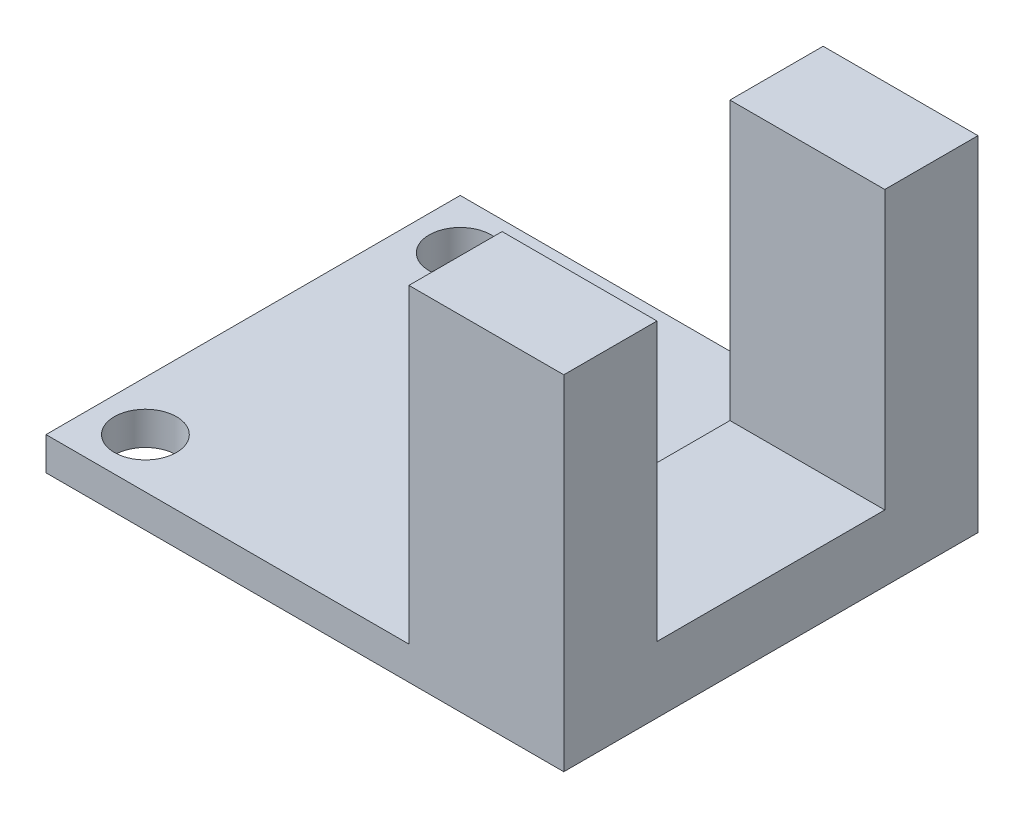
from build123d import *

# Parameters (mm, degrees)
SKETCH1_W           = 25
SKETCH1_H           = 20
BOSS_EXTRUDE1_DEPTH = 1.6
SKETCH2_W           = 7.477117313
SKETCH2_H           = 20
BOSS_EXTRUDE2_DEPTH = 15
SKETCH3_W           = 11
SKETCH3_H           = 13.40236223
CUT_EXTRUDE1_DEPTH  = 15
SKETCH4_R           = 1.5
CUT_EXTRUDE2_DEPTH  = 15


with BuildPart() as part:
    # Sketch1 → Boss-Extrude1 (new body)
    with BuildSketch(Plane(origin=(0, 0, 0), x_dir=(1, 0, 0), z_dir=(0, 1, 0))):
        Rectangle(SKETCH1_W, SKETCH1_H)
    extrude(amount=BOSS_EXTRUDE1_DEPTH)

    # Sketch2 → Boss-Extrude2 (add)
    with BuildSketch(Plane(origin=(0, 1.6, 0), x_dir=(1, 0, 0), z_dir=(0, 1, 0))):
        with Locations((8.761441343, 0)):
            Rectangle(SKETCH2_W, SKETCH2_H)
    extrude(amount=BOSS_EXTRUDE2_DEPTH)

    # Sketch3 → Cut-Extrude1 (cut)
    with BuildSketch(Plane(origin=(12.5, 0, 0), x_dir=(0, 0, -1), z_dir=(1, 0, 0))):
        with Locations((0, 9.898818885)):
            Rectangle(SKETCH3_W, SKETCH3_H)
    extrude(amount=-CUT_EXTRUDE1_DEPTH, mode=Mode.SUBTRACT)

    # Sketch4 → Cut-Extrude2 (cut)
    with BuildSketch(Plane(origin=(0, 1.6, 0), x_dir=(1, 0, 0), z_dir=(0, 1, 0))):
        with Locations((-10.1, 7.6)):
            Circle(SKETCH4_R)
        with Locations((-10.1, -7.6)):
            Circle(SKETCH4_R)
    extrude(amount=-CUT_EXTRUDE2_DEPTH, mode=Mode.SUBTRACT)


solid = part.part
